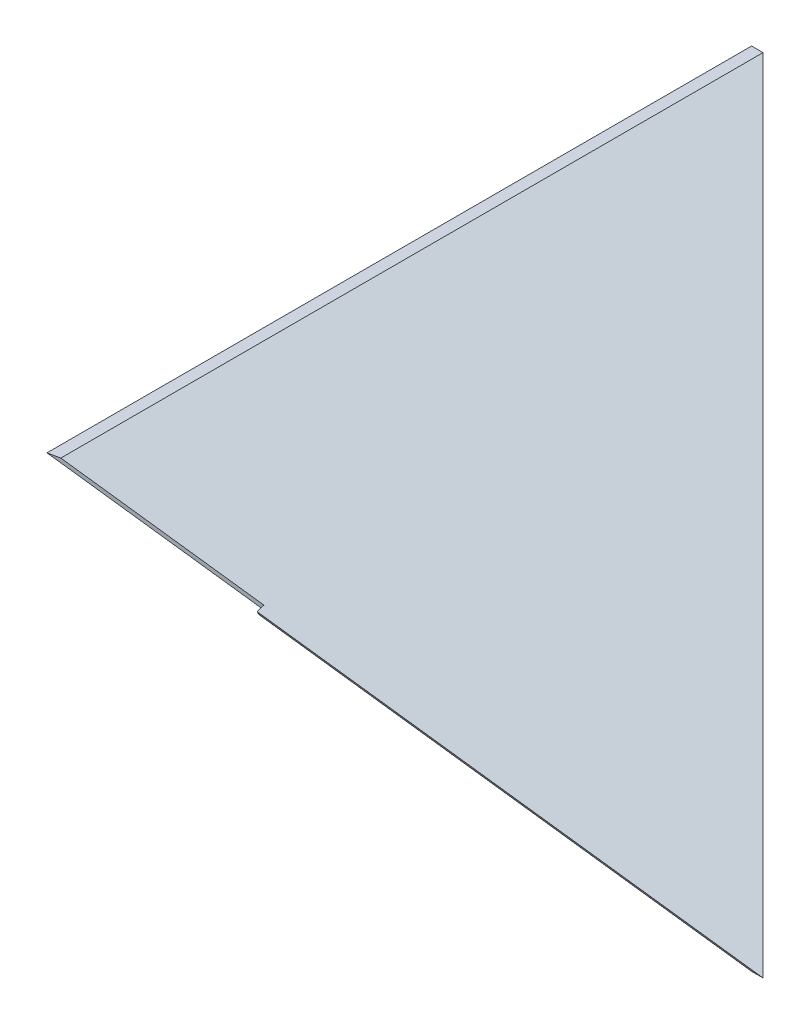
from build123d import *

# Parameters (mm, degrees)
BOSS_EXTRUDE1_DEPTH     = 304.8
CUT_EXTRUDE1_DEPTH      = 198.18
CUT_EXTRUDE1_DEPTH_BACK = 1
CUT_EXTRUDE4_DEPTH      = 60.305329017


with BuildPart() as part:
    # Sketch1 → Boss-Extrude1 (new body)
    with BuildSketch(Plane(origin=(0, 0, 0), x_dir=(0, 0, -1), z_dir=(1, 0, 0))):
        Polygon((0, 0), (-197.18, 0), (-162.940052328, -59.305329017), align=None)
    extrude(amount=BOSS_EXTRUDE1_DEPTH)

    # Sketch2 → Cut-Extrude1 (cut, two sides)
    with BuildSketch(Plane.XY) as cut_extrude1_sk:
        Polygon((0, 0), (162.940052328, -59.305329017), (0, -59.305329017), align=None)
        Polygon((166.115052328, -59.305329017), (3.175, 0), (304.8, 0), (304.8, -59.305329017), align=None)
    extrude(amount=CUT_EXTRUDE1_DEPTH, mode=Mode.SUBTRACT)
    extrude(cut_extrude1_sk.sketch, amount=-CUT_EXTRUDE1_DEPTH_BACK, mode=Mode.SUBTRACT)

    # Sketch4 → Cut-Extrude4 (cut, through all)
    with BuildSketch(Plane(origin=(0, 0, 0), x_dir=(1, 0, 0), z_dir=(0, 1, 0))):
        Polygon((50.203910812, -187.297424032), (49.714214198, -184.967070242), (0, -195.413931332), (0, -197.18), (3.175, -197.18), align=None)
    extrude(amount=-CUT_EXTRUDE4_DEPTH, mode=Mode.SUBTRACT)


solid = part.part
